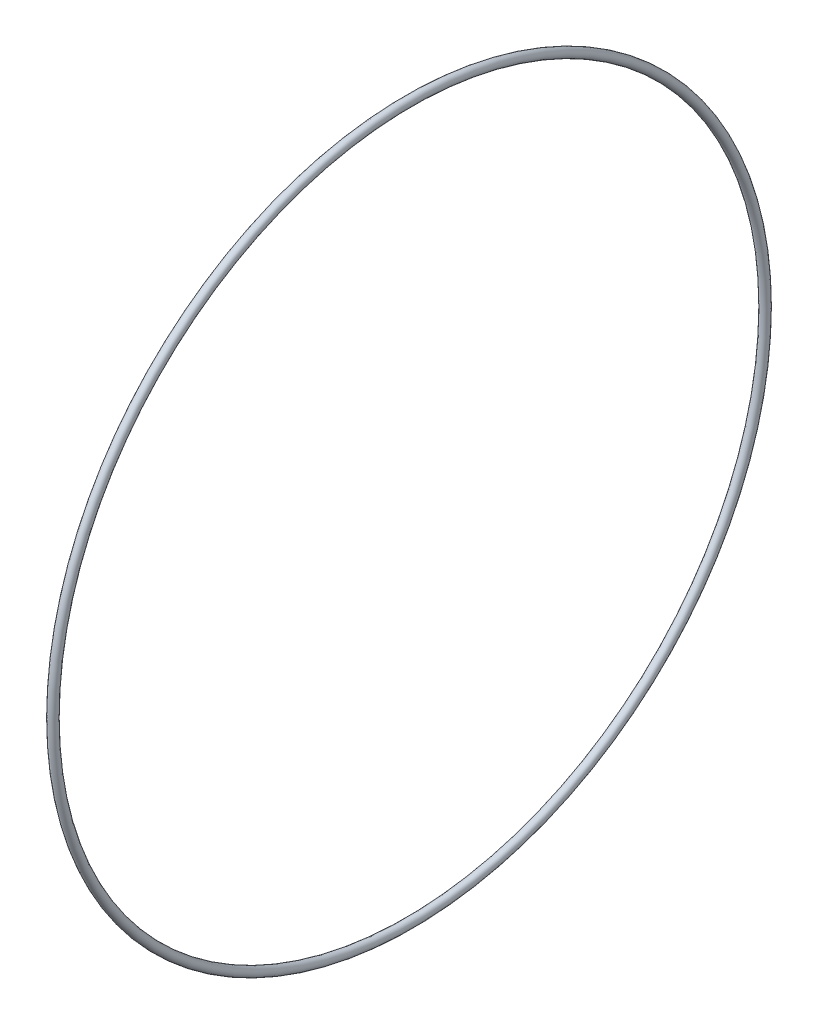
from build123d import *

# Parameters (mm, degrees)
SWEEP_1_PROFILE_R = 2.5


with BuildPart() as part:
    # 扫描1: sweep along a path in 草图1
    with BuildLine(Plane(origin=(0, 0, 0), x_dir=(0, 0, -1), z_dir=(1, 0, 0))) as sweep_1_path:
        CenterArc((0, 0), 200, 0, 360)
    # 扫描1 profile (on start of the path) → 扫描1 (sweep)
    with BuildSketch(Plane(origin=(0, 0, -200), x_dir=(0, 0, 1), z_dir=(0, 1, 0))):
        Circle(SWEEP_1_PROFILE_R)
    sweep(path=sweep_1_path.line)


solid = part.part
